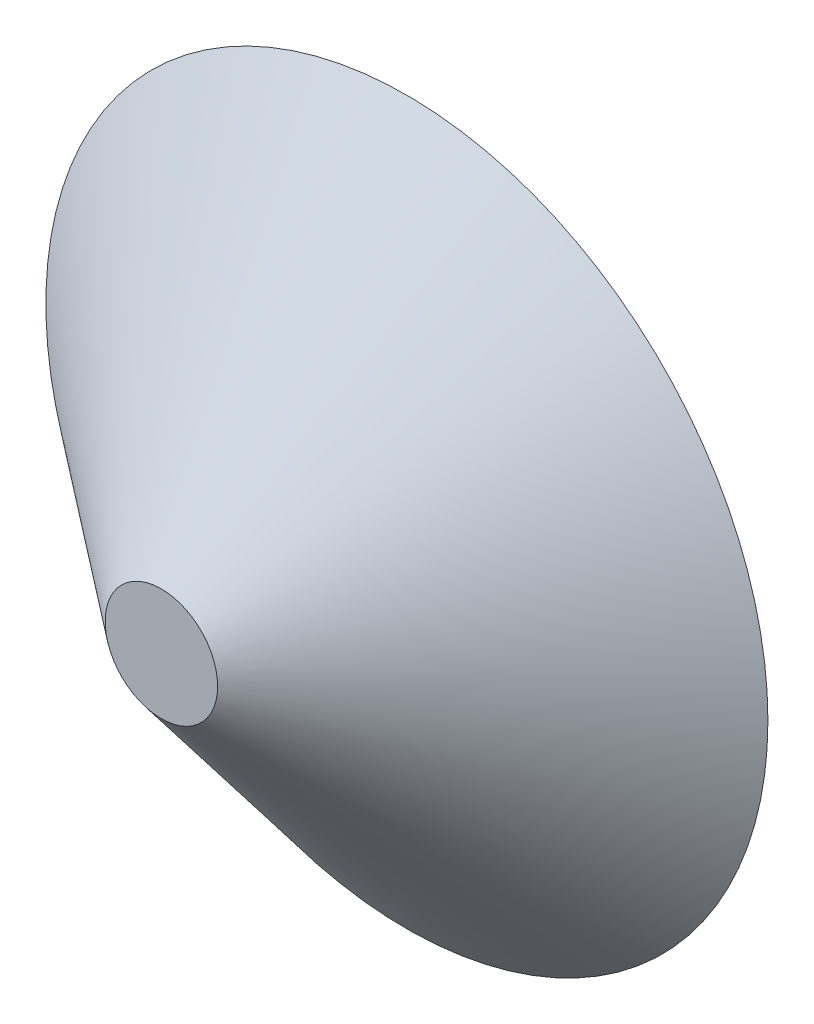
from build123d import *

# Parameters (mm, degrees)
SKETCH1_R           = 140
BOSS_EXTRUDE4_DEPTH = 95.2
BOSS_EXTRUDE4_TAPER = 51.15
SHELL5_T            = -1.88


with BuildPart() as part:
    # Sketch1 → Boss-Extrude4 (new body)
    with BuildSketch(Plane.XY):
        Circle(SKETCH1_R)
    extrude(amount=BOSS_EXTRUDE4_DEPTH, taper=BOSS_EXTRUDE4_TAPER)

    # Shell5
    shell5_openings = [part.faces().sort_by_distance(p)[0] for p in [
        (140, 0, 0),
    ]]
    offset(amount=SHELL5_T, openings=shell5_openings, kind=Kind.INTERSECTION)


solid = part.part
